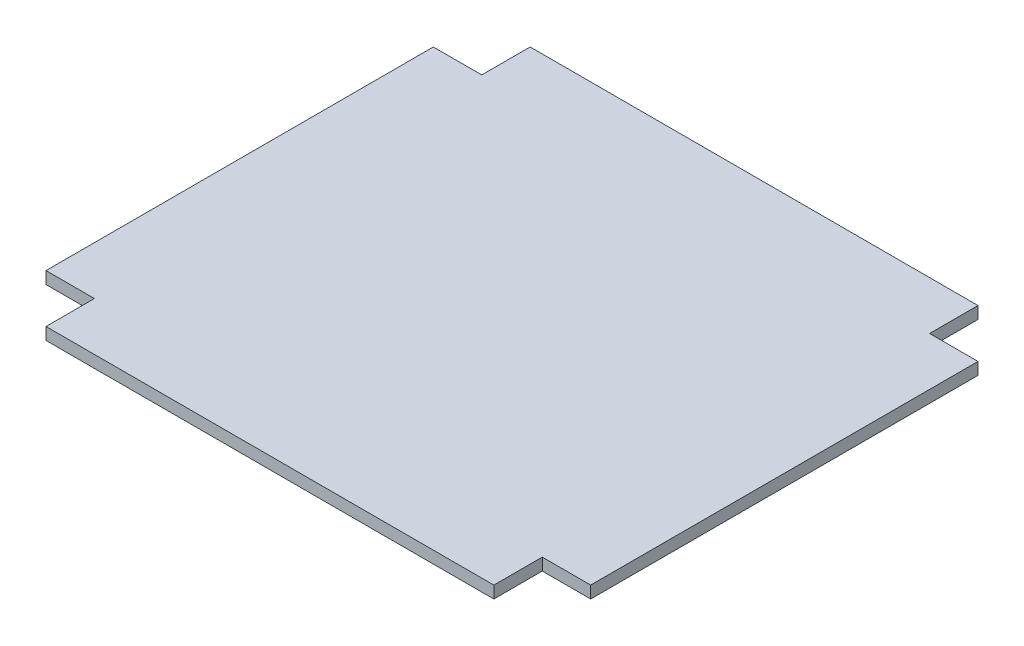
from build123d import *

# Parameters (mm, degrees)
SALIENTE_EXTRUIR1_DEPTH = 6.35


with BuildPart() as part:
    # Croquis1 → Saliente-Extruir1 (new body)
    with BuildSketch(Plane(origin=(0, 0, 0), x_dir=(1, 0, 0), z_dir=(0, 1, 0))):
        Polygon((120.65, 127), (-114.3, 127), (-114.3, 101.6), (-139.7, 101.6), (-139.7, -101.6), (-114.3, -101.6), (-114.3, -127), (120.65, -127), (120.65, -101.6), (146.05, -101.6), (146.05, 101.6), (120.65, 101.6), align=None)
    extrude(amount=SALIENTE_EXTRUIR1_DEPTH)


solid = part.part
